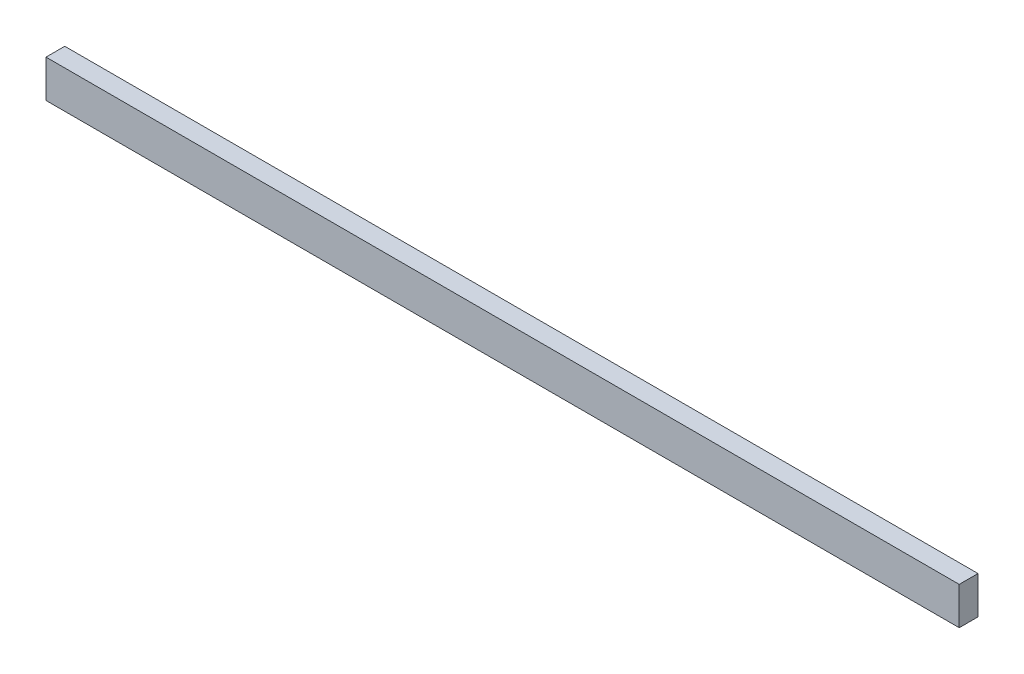
from build123d import *

# Parameters (mm, degrees)
SKETCH1_W           = 1234.940816721
SKETCH1_H           = 25.4
BOSS_EXTRUDE2_DEPTH = 50.8


with BuildPart() as part:
    # Sketch1 → Boss-Extrude2 (new body)
    with BuildSketch(Plane(origin=(0, 0, 0), x_dir=(1, 0, 0), z_dir=(0, 1, 0))):
        with Locations((617.470408361, 12.7)):
            Rectangle(SKETCH1_W, SKETCH1_H)
    extrude(amount=BOSS_EXTRUDE2_DEPTH)


solid = part.part
